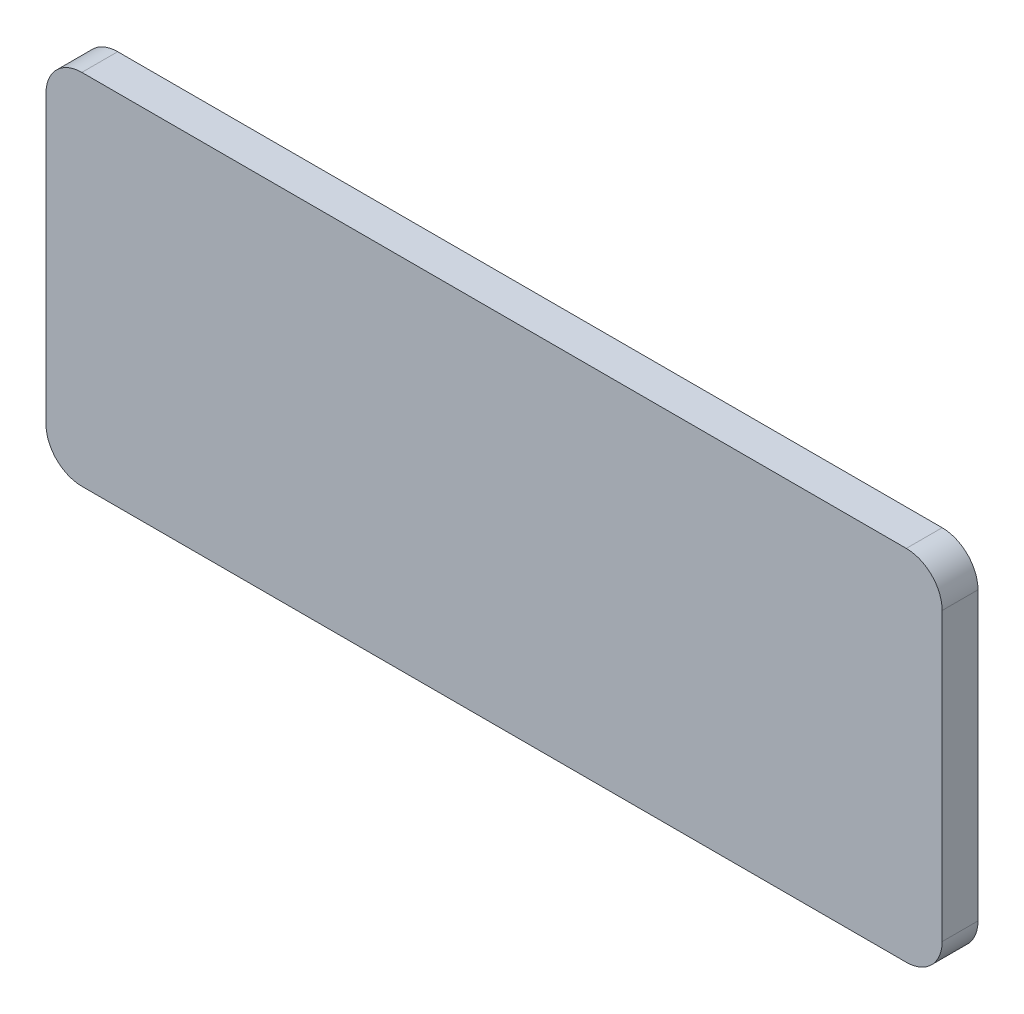
from build123d import *

# Parameters (mm, degrees)
ESQUISSE1_W        = 50
ESQUISSE1_H        = 20
BOSS_EXTRU_1_DEPTH = 2
CONG_1_R           = 2


with BuildPart() as part:
    # Esquisse1 → Boss.-Extru.1 (new body)
    with BuildSketch(Plane.XY):
        Rectangle(ESQUISSE1_W, ESQUISSE1_H)
    extrude(amount=BOSS_EXTRU_1_DEPTH)

    # Congé1
    cong_1_edges = [part.edges().sort_by_distance(p)[0] for p in [
        (25, -10, 1),
        (-25, -10, 1),
        (-25, 10, 1),
        (25, 10, 1),
    ]]
    fillet(cong_1_edges, radius=CONG_1_R)


solid = part.part
